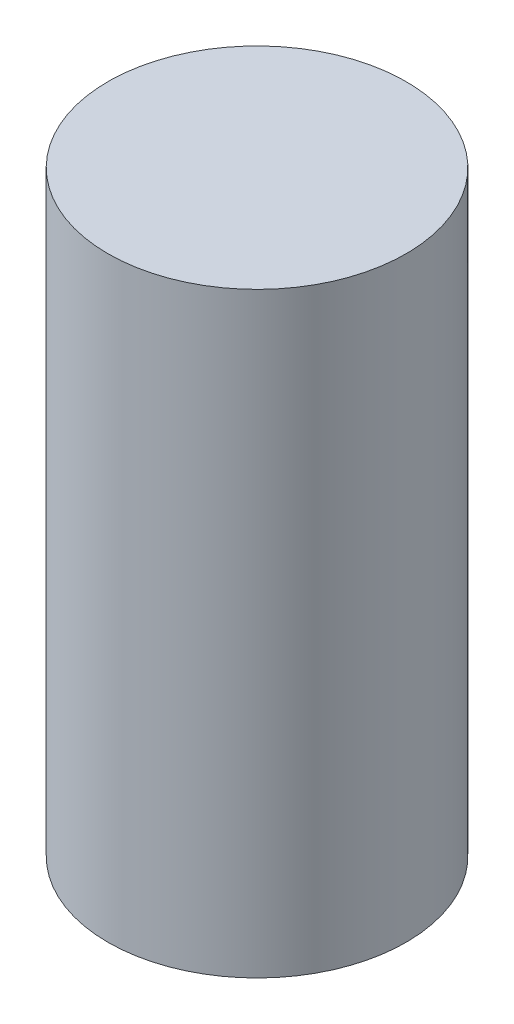
from build123d import *

# Parameters (mm, degrees)
SKIZZE1_R                       = 50
AUFSATZ_LINEAR_AUSTRAGEN1_DEPTH = 200


with BuildPart() as part:
    # Skizze1 → Aufsatz-Linear austragen1 (new body)
    with BuildSketch(Plane(origin=(0, 0, 0), x_dir=(1, 0, 0), z_dir=(0, 1, 0))):
        with Locations(Location((0, 0, 0), (0, 0, 270))):  # turned: the seam where the file's is
            Circle(SKIZZE1_R)
    extrude(amount=AUFSATZ_LINEAR_AUSTRAGEN1_DEPTH)


solid = part.part
